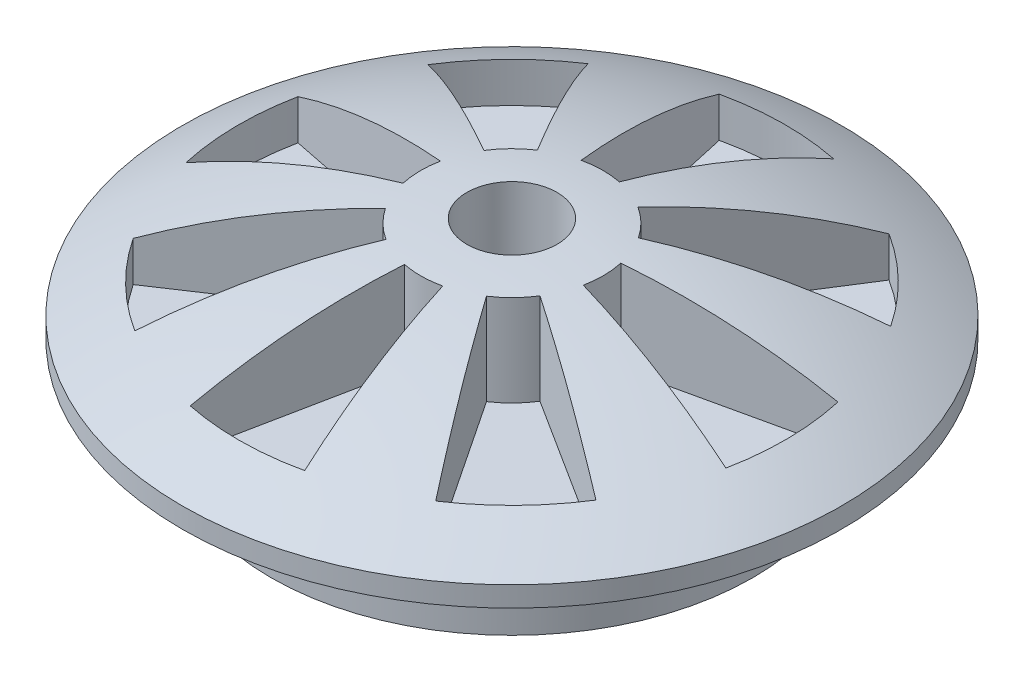
from build123d import *

# Parameters (mm, degrees)
CUT_EXTRUDE3_START = -28.048647
CUT_EXTRUDE3_DEPTH = 25.508647
CIRPATTERN2_COUNT  = 8
CUT_EXTRUDE4_REACH = 31.45
SKETCH6_R          = 12.59210321
SCALE1_SCALE       = 0.96551724


with BuildPart() as part:
    # Sketch1 → Revolve1 (revolve)
    with BuildSketch(Plane.XY, mode=Mode.PRIVATE) as revolve1_sk:
        with BuildLine():
            Line((-92.075, 0), (-92.075, -5.649667396))
            Line((-92.075, -5.649667396), (-67.31, -5.649667396))
            Line((-67.31, -5.649667396), (-67.31, -29.740701954))
            Line((-67.31, -29.740701954), (0, -29.740701954))
            Line((0, -29.740701954), (0, 0))
            Line((0, 0), (0, 23.771242064))
            ThreePointArc((0, 23.771242064), (-47.656193975, 18.155434253), (-92.075, 0))
        make_face()
    revolve(revolve1_sk.sketch.rotate(Axis((0, 46.369911649, 0), (0, -1, 0)), 270), axis=Axis((0, 46.369911649, 0), (0, -1, 0)))  # turned: the seam where the file's is

    # Sketch4 → Cut-Extrude3 (cut)
    with BuildSketch(Plane.XZ.offset(5.649667396).offset(CUT_EXTRUDE3_START)):
        with BuildLine():
            Line((24.987766053, 5.028443659), (74.822826668, 15.057063026))
            ThreePointArc((74.822826668, 15.057063026), (76.318746359, -0.787077909), (74.496377234, -16.596997215))
            Line((74.496377234, -16.596997215), (24.878745284, -5.542718741))
            ThreePointArc((24.878745284, -5.542718741), (25.487342091, -0.262851853), (24.987766053, 5.028443659))
        make_face()
    cut_extrude3 = extrude(amount=CUT_EXTRUDE3_DEPTH, mode=Mode.SUBTRACT)

    # CirPattern2: Cut-Extrude3 ×8 about axis
    cirpattern2_axis = Axis((0, 0, 0), (0, 1, 0))
    for i in range(1, CIRPATTERN2_COUNT):
        add(cut_extrude3.rotate(cirpattern2_axis, i * 360 / CIRPATTERN2_COUNT), mode=Mode.SUBTRACT)

    # Sketch6 → Cut-Extrude4 (cut, up to next)
    with BuildSketch(Plane.XZ.offset(5.649667396), mode=Mode.PRIVATE) as cut_extrude4_sk1:
        with Locations(Location((0, 0, 0), (0, 0, 270))):  # turned: the seam where the file's is
            Circle(SKETCH6_R)
    cut_extrude4_tool1 = extrude(cut_extrude4_sk1.sketch, amount=-CUT_EXTRUDE4_REACH, mode=Mode.PRIVATE) & part.part
    add(cut_extrude4_tool1.solids().sort_by_distance((0, -5.649667, 0))[0], mode=Mode.SUBTRACT)


with BuildPart() as part_1:
    # Scale1: scaled about (-5e-09, -7.646574392, 0)
    add(part.part.scale(SCALE1_SCALE).moved(Location((0, -0.26367499, 0))))


solid = part_1.part
